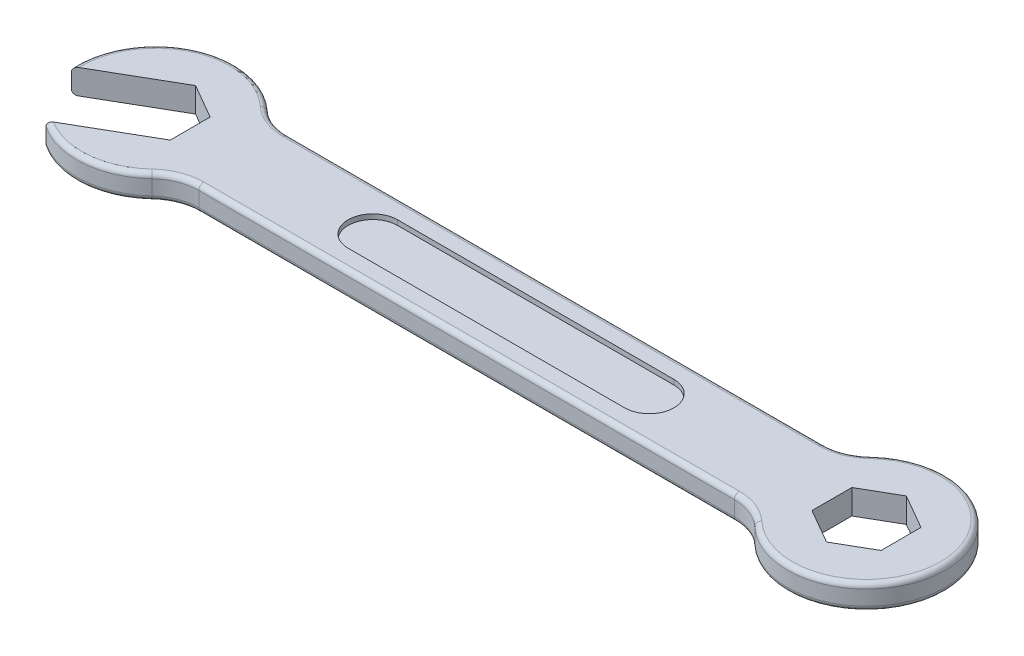
from build123d import *

# Parameters (mm, degrees)
BOSS_EXTRUDE1_DEPTH = 1.25
FILLET1_R           = 5
FILLET2_R           = 0.5
CUT_EXTRUDE1_DEPTH  = 0.5


with BuildPart() as part:
    # Sketch1 → Boss-Extrude1 (new body, symmetric)
    with BuildSketch(Plane(origin=(0, 0, 0), x_dir=(1, 0, 0), z_dir=(0, 1, 0))):
        with BuildLine():
            Line((6.614378278, 4.5), (65.385621722, 4.5))
            ThreePointArc((65.385621722, 4.5), (80, 0), (65.385621722, -4.5))
            Line((65.385621722, -4.5), (6.614378278, -4.5))
            ThreePointArc((6.614378278, -4.5), (1.506978128, -7.856781588), (-4.479967897, -6.627962556))
            Line((-4.479967897, -6.627962556), (3.5, -2.020725942))
            Line((3.5, -2.020725942), (3.5, 2.020725942))
            Line((3.5, 2.020725942), (0, 4.041451884))
            Line((0, 4.041451884), (-7.979967897, -0.565784729))
            ThreePointArc((-7.979967897, -0.565784729), (-2.623309452, 7.557661511), (6.614378278, 4.5))
        make_face()
        Polygon((72, 4.041451884), (68.5, 2.020725942), (68.5, -2.020725942), (72, -4.041451884), (75.5, -2.020725942), (75.5, 2.020725942), align=None, mode=Mode.SUBTRACT)
    extrude(amount=BOSS_EXTRUDE1_DEPTH, both=True)

    # Fillet1
    fillet1_edges = [part.edges().sort_by_distance(p)[0] for p in [
        (6.614378278, 0, -4.5),
        (65.385621722, 0, -4.5),
        (65.385621722, 0, 4.5),
        (6.614378278, 0, 4.5),
    ]]
    fillet(fillet1_edges, radius=FILLET1_R)

    # Fillet2
    fillet2_edges = [part.edges().sort_by_distance(p)[0] for p in [
        (0.627224524, 1.25, 7.975373935),
        (36, -1.25, -4.5),
        (36, 1.25, -4.5),
        (80, -1.25, 0),
        (80, 1.25, 0),
        (36, -1.25, 4.5),
        (36, 1.25, 4.5),
        (-3.444494595, -1.25, -7.220488694),
        (-3.444494595, 1.25, -7.220488694),
        (64.96037879, -1.25, -4.848697453),
        (64.96037879, 1.25, -4.848697453),
        (64.96037879, -1.25, 4.848697453),
        (64.96037879, 1.25, 4.848697453),
        (7.03962121, -1.25, 4.848697453),
        (7.03962121, 1.25, 4.848697453),
        (7.03962121, -1.25, -4.848697453),
        (7.03962121, 1.25, -4.848697453),
        (0.627224524, -1.25, 7.975373935),
    ]]
    fillet(fillet2_edges, radius=FILLET2_R)

    # Sketch2 → Cut-Extrude1 (cut)
    with BuildSketch(Plane(origin=(0, 1.25, 0), x_dir=(1, 0, 0), z_dir=(0, 1, 0))):
        with BuildLine():
            Line((22, 2.5), (50, 2.5))
            ThreePointArc((50, 2.5), (52.5, 0), (50, -2.5))
            Line((50, -2.5), (22, -2.5))
            ThreePointArc((22, -2.5), (19.5, 0), (22, 2.5))
        make_face()
    cut_extrude1 = extrude(amount=-CUT_EXTRUDE1_DEPTH, mode=Mode.SUBTRACT)

    # Mirror1: Cut-Extrude1 across plane
    add(cut_extrude1.mirror(Plane.ZX), mode=Mode.SUBTRACT)


solid = part.part
